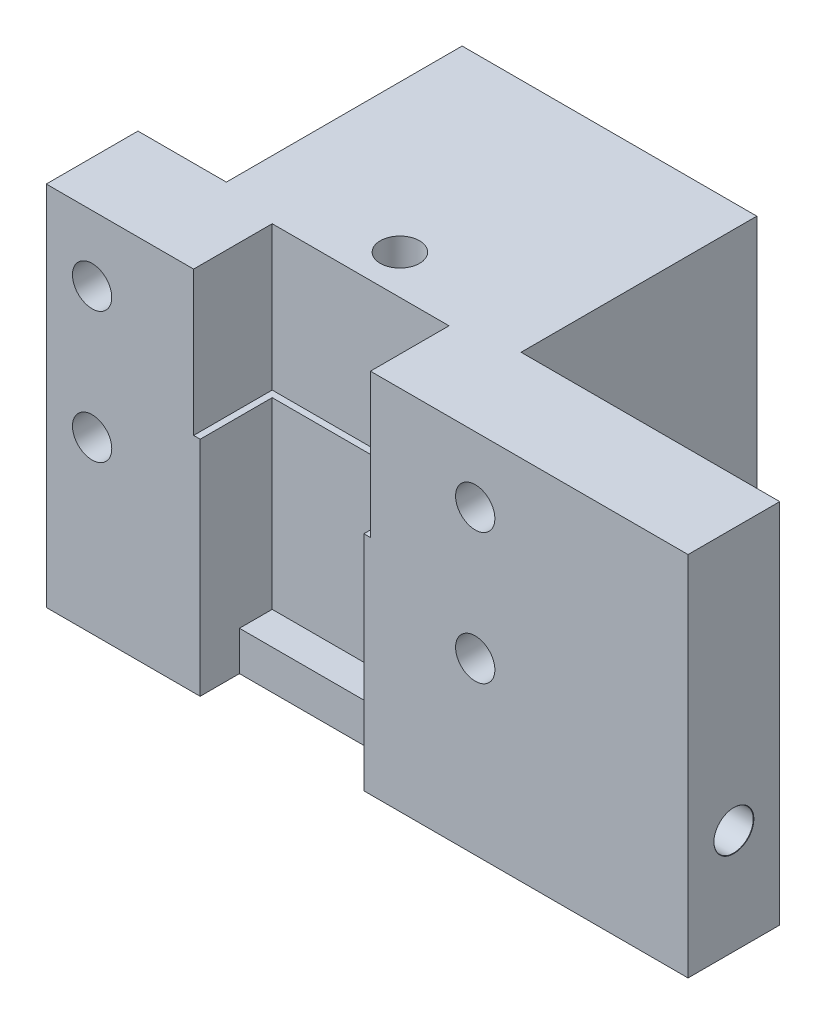
from build123d import *

# Parameters (mm, degrees)
SKETCH1_W                       = 49
SKETCH1_H                       = 25
BOSS_EXTRUDE1_DEPTH             = 28
SKETCH2_W                       = 12.5
SKETCH2_H                       = 5.5
CUT_EXTRUDE1_DEPTH              = 25
F_3_0MM_DOWEL_HOLE1_D           = 3
F_3_0MM_DOWEL_HOLE1_DEPTH       = 11.098709071
F_3_0MM_DOWEL_HOLE1_CSINK_D     = 3.05
F_3_0MM_DOWEL_HOLE1_CSINK_ANGLE = 90
F_3_0MM_DOWEL_HOLE1_TIP         = 0.901290929
F_3_0MM_DOWEL_HOLE2_D           = 3
F_3_0MM_DOWEL_HOLE2_DEPTH       = 24.75
F_3_0MM_DOWEL_HOLE2_CSINK_D     = 3.05
F_3_0MM_DOWEL_HOLE2_CSINK_ANGLE = 90
F_3_0MM_DOWEL_HOLE3_D           = 3
F_3_0MM_DOWEL_HOLE3_CSINK_D     = 3.05
F_3_0MM_DOWEL_HOLE3_CSINK_ANGLE = 90
SKETCH13_R                      = 1.5
CUT_EXTRUDE2_DEPTH              = 12
SKETCH14_W                      = 6.75
SKETCH14_H                      = 18
SKETCH14_W_2                    = 19.75
CUT_EXTRUDE3_DEPTH              = 28
SKETCH15_W                      = 12.5
SKETCH15_H                      = 3
CUT_EXTRUDE4_DEPTH              = 10
CUT_EXTRUDE5_DEPTH              = 11


with BuildPart() as part:
    # Sketch1 → Boss-Extrude1 (new body)
    with BuildSketch(Plane(origin=(0, 0, 0), x_dir=(1, 0, 0), z_dir=(0, 1, 0))):
        with Locations((13.974428044, -0.190405904)):
            Rectangle(SKETCH1_W, SKETCH1_H)
    extrude(amount=BOSS_EXTRUDE1_DEPTH)

    # Sketch2 → Cut-Extrude1 (cut)
    with BuildSketch(Plane(origin=(0, 28, 0), x_dir=(1, 0, 0), z_dir=(0, 1, 0))):
        with Locations((7.474428044, -9.940405904)):
            Rectangle(SKETCH2_W, SKETCH2_H)
    extrude(amount=-CUT_EXTRUDE1_DEPTH, mode=Mode.SUBTRACT)

    # Ø3.0mm Dowel Hole1
    with Locations(Plane(origin=(0, 0, -12.309594096), x_dir=(-1, 0, 0), z_dir=(0, 0, -1))):
        with Locations((-7.474428044, 16)):
            CounterSinkHole(F_3_0MM_DOWEL_HOLE1_D / 2, F_3_0MM_DOWEL_HOLE1_CSINK_D / 2, depth=F_3_0MM_DOWEL_HOLE1_DEPTH, counter_sink_angle=F_3_0MM_DOWEL_HOLE1_CSINK_ANGLE)
            with Locations((0, 0, -(F_3_0MM_DOWEL_HOLE1_DEPTH + F_3_0MM_DOWEL_HOLE1_TIP / 2))):  # 118° drill point
                Cone(0, F_3_0MM_DOWEL_HOLE1_D / 2, F_3_0MM_DOWEL_HOLE1_TIP, mode=Mode.SUBTRACT)

    # Ø3.0mm Dowel Hole2
    with Locations(Plane(origin=(38.474428044, 0, 0), x_dir=(0, 0, -1), z_dir=(1, 0, 0))):
        with Locations((-9.190405904, 8)):
            CounterSinkHole(F_3_0MM_DOWEL_HOLE2_D / 2, F_3_0MM_DOWEL_HOLE2_CSINK_D / 2, depth=F_3_0MM_DOWEL_HOLE2_DEPTH, counter_sink_angle=F_3_0MM_DOWEL_HOLE2_CSINK_ANGLE)

    # Ø3.0mm Dowel Hole3 (through all)
    with Locations(Plane(origin=(0, 0, 0), x_dir=(-1, 0, 0), z_dir=(0, -1, 0))):
        with Locations((-7.474428044, -3.690405904)):
            CounterSinkHole(F_3_0MM_DOWEL_HOLE3_D / 2, F_3_0MM_DOWEL_HOLE3_CSINK_D / 2, counter_sink_angle=F_3_0MM_DOWEL_HOLE3_CSINK_ANGLE)

    # Sketch13 → Cut-Extrude2 (cut)
    with BuildSketch(Plane.XY.offset(12.690405904)):
        with Locations((-7.025571956, 23)):
            Circle(SKETCH13_R)
        with Locations((-7.025571956, 13)):
            Circle(SKETCH13_R)
        with Locations((22.224428044, 23)):
            Circle(SKETCH13_R)
        with Locations((22.224428044, 13)):
            Circle(SKETCH13_R)
    extrude(amount=-CUT_EXTRUDE2_DEPTH, mode=Mode.SUBTRACT)

    # Sketch14 → Cut-Extrude3 (cut)
    with BuildSketch(Plane(origin=(0, 28, 0), x_dir=(1, 0, 0), z_dir=(0, 1, 0))):
        with Locations((-7.150571956, 3.309594096)):
            Rectangle(SKETCH14_W, SKETCH14_H)
        with Locations((28.599428044, 3.309594096)):
            Rectangle(SKETCH14_W_2, SKETCH14_H)
    extrude(amount=-CUT_EXTRUDE3_DEPTH, mode=Mode.SUBTRACT)

    # Sketch15 → Cut-Extrude4 (cut)
    with BuildSketch(Plane(origin=(0, 3, 0), x_dir=(1, 0, 0), z_dir=(0, 1, 0))):
        with Locations((7.474428044, -11.190405904)):
            Rectangle(SKETCH15_W, SKETCH15_H)
    extrude(amount=-CUT_EXTRUDE4_DEPTH, mode=Mode.SUBTRACT)

    # Sketch16 → Cut-Extrude5 (cut)
    with BuildSketch(Plane(origin=(0, 28, 0), x_dir=(1, 0, 0), z_dir=(0, 1, 0))):
        Polygon((14.224428044, -12.690405904), (14.224428044, -6.690405904), (0.724428044, -6.690405904), (0.724428044, -12.690405904), (1.224428044, -12.690405904), (1.224428044, -7.190405904), (13.724428044, -7.190405904), (13.724428044, -12.690405904), align=None)
    extrude(amount=-CUT_EXTRUDE5_DEPTH, mode=Mode.SUBTRACT)


solid = part.part
